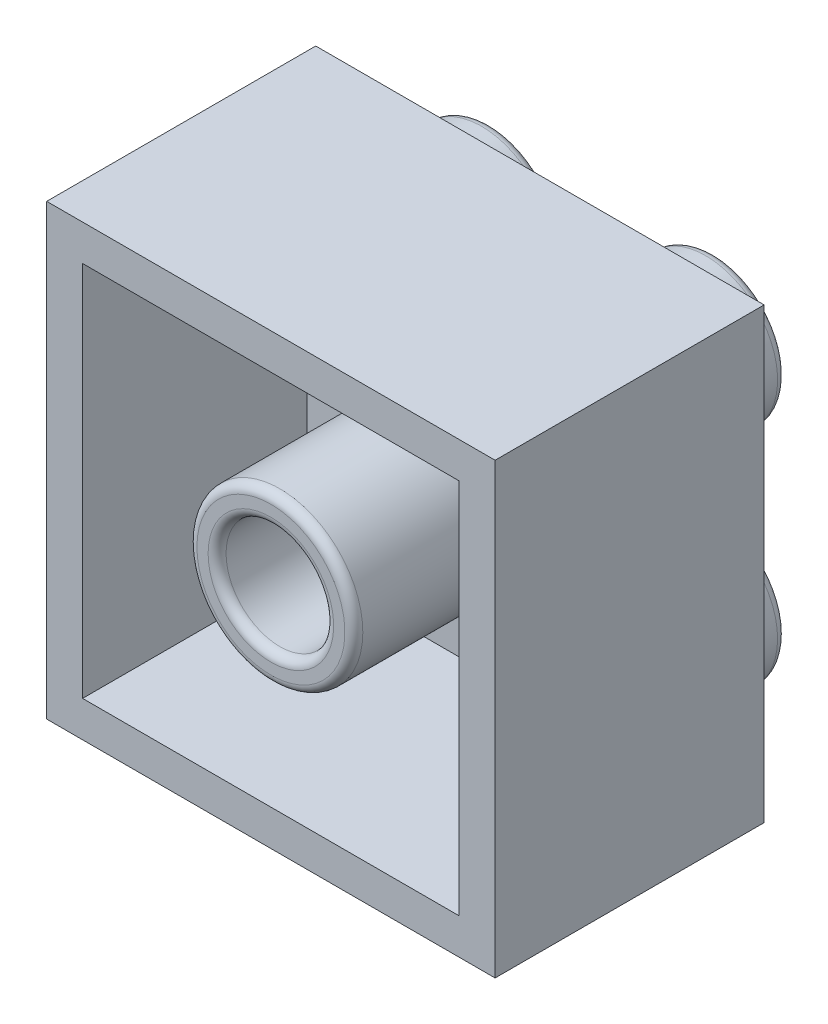
from build123d import *

# Parameters (mm, degrees)
ESQUISSE2_W             = 100
ESQUISSE2_H             = 100
BOSS_EXTRU_1_DEPTH      = 60
ESQUISSE3_R             = 16
BOSS_EXTRU_3_DEPTH      = 14
ESQUISSE4_W             = 84
ESQUISSE4_H             = 84
ESQUISSE4_R             = 18.5
ESQUISSE4_R_2           = 12
ENL_V_MAT_EXTRU_1_DEPTH = 50
CONG_2_R                = 2


with BuildPart() as part:
    # Esquisse2 → Boss.-Extru.1 (new body)
    with BuildSketch(Plane.XY):
        Rectangle(ESQUISSE2_W, ESQUISSE2_H)
    extrude(amount=BOSS_EXTRU_1_DEPTH)

    # Esquisse3 → Boss.-Extru.3 (add)
    with BuildSketch(Plane(origin=(0, 0, 0), x_dir=(-1, 0, 0), z_dir=(0, 0, -1))):
        with Locations((-25, 25)):
            Circle(ESQUISSE3_R)
        with Locations((-25, -25)):
            Circle(ESQUISSE3_R)
        with Locations((25, 25)):
            Circle(ESQUISSE3_R)
        with Locations((25, -25)):
            Circle(ESQUISSE3_R)
    extrude(amount=BOSS_EXTRU_3_DEPTH)

    # Esquisse4 → Enlèv. mat.-Extru.1 (cut)
    with BuildSketch(Plane.XY.offset(60)):
        Rectangle(ESQUISSE4_W, ESQUISSE4_H)
        Circle(ESQUISSE4_R, mode=Mode.SUBTRACT)
        Circle(ESQUISSE4_R_2)
    extrude(amount=-ENL_V_MAT_EXTRU_1_DEPTH, mode=Mode.SUBTRACT)

    # Congé2
    cong_2_edges = [part.edges().sort_by_distance(p)[0] for p in [
        (41, -25, 0),
        (41, -25, -14),
        (-9, 25, 0),
        (-9, 25, -14),
        (-9, -25, 0),
        (-9, -25, -14),
        (41, 25, 0),
        (41, 25, -14),
        (-12, 0, 10),
        (-12, 0, 60),
        (-18.5, 0, 60),
        (-18.5, 0, 10),
    ]]
    fillet(cong_2_edges, radius=CONG_2_R)


solid = part.part
